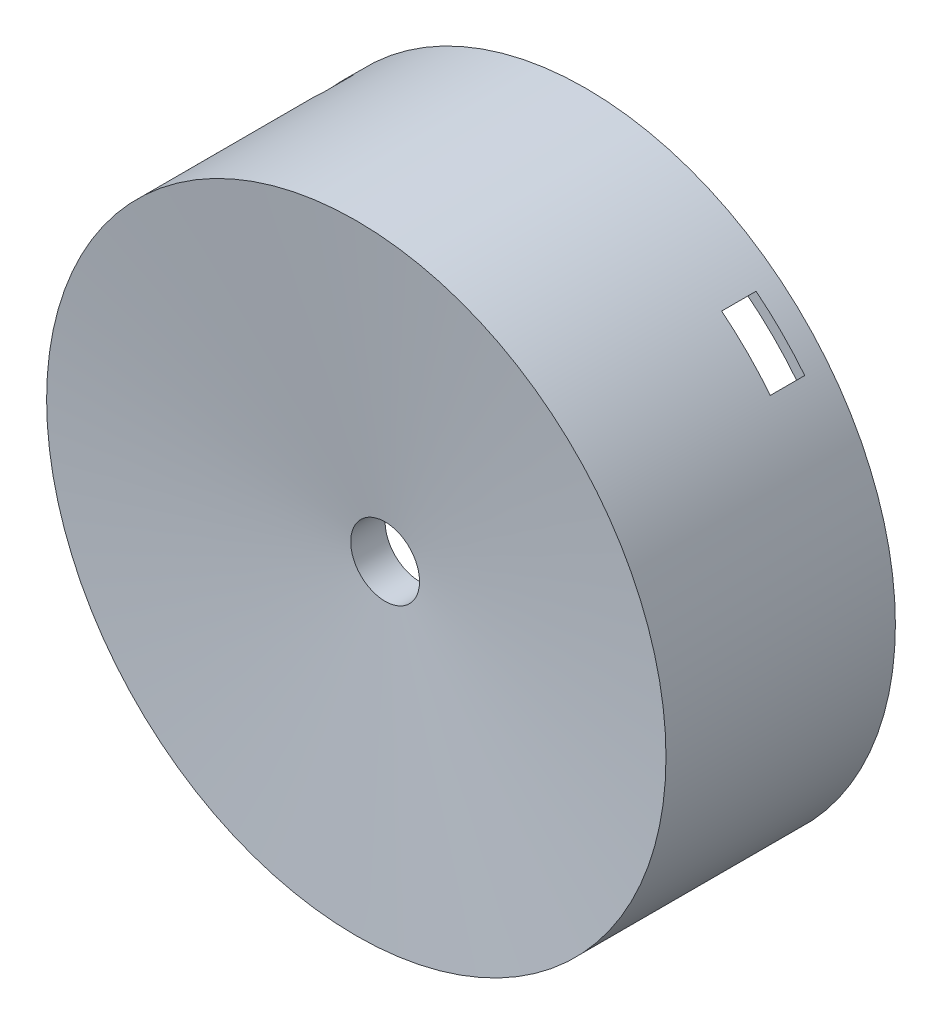
from build123d import *

# Parameters (mm, degrees)
BOSS_EXTRU_4_START      = -13.837467
BOSS_EXTRU_4_DEPTH      = 13.837467
ENL_V_MAT_EXTRU_2_DEPTH = 3
ENL_V_MAT_EXTRU_3_DEPTH = 3


with BuildPart() as part:
    # Esquisse3 → Révolution1 (revolve)
    with BuildSketch(Plane(origin=(0, 0, 0), x_dir=(1, 0, 0), z_dir=(0, 1, 0))):
        Polygon((-27, 18.413817), (-27, 38.413817), (-26, 38.413817), (-26, 33.413817), (-25.5, 33.413817), (-25.5, 19.57635), (-3.5, 21.879977), (-3.5, 23.926865), (-3, 23.926865), (-3, 20.926865), align=None)
    revolve(axis=Axis((0, 0, 0), (0, 0, -1)))

    # Esquisse7 → Boss.-Extru.4 (add)
    with BuildSketch(Plane(origin=(0, 0, -33.413817), x_dir=(-1, 0, 0), z_dir=(0, 0, -1)).offset(BOSS_EXTRU_4_START)):
        Polygon((22.922963, -1), (25.922963, -2), (25.922963, 2), (22.922963, 1), align=None)
        Polygon((-21.922971, 0.990749), (-24.919872, 2), (-24.932213, -1.999981), (-21.929142, -1.009241), align=None)
        Polygon((19.48304, 10.094527), (22.581242, 10.727885), (20.581931, 14.192384), (18.483384, 11.826776), align=None)
        Polygon((-18.489986, 11.81993), (-20.581242, 14.191987), (-22.591207, 10.733658), (-19.494969, 10.090766), align=None)
        Polygon((18.497253, -11.813544), (20.581242, -14.191987), (22.363748, -11.146506), (22.601778, -10.739823), (19.507521, -10.087462), align=None)
        Polygon((-19.481096, -10.10411), (-22.581242, -10.727885), (-20.592654, -14.19855), (-18.486802, -11.839443), align=None)
    extrude(amount=BOSS_EXTRU_4_DEPTH)

    # Esquisse8 → Enlèv. mat.-Extru.2 (cut)
    with BuildSketch(Plane(origin=(0, 0, -33.413817), x_dir=(-1, 0, 0), z_dir=(0, 0, -1))):
        Polygon((10.264649, 12.385969), (23.674383, 25.795703), (25.795703, 23.674383), (12.385969, 10.264649), align=None)
    extrude(amount=ENL_V_MAT_EXTRU_2_DEPTH, mode=Mode.SUBTRACT)

    # Esquisse9 → Enlèv. mat.-Extru.3 (cut)
    with BuildSketch(Plane(origin=(0, 0, -33.413817), x_dir=(-1, 0, 0), z_dir=(0, 0, -1))):
        Polygon((-12.020815, 16.263456), (-19.091883, 23.334524), (-23.334524, 19.091883), (-16.263456, 12.020815), align=None)
    extrude(amount=ENL_V_MAT_EXTRU_3_DEPTH, mode=Mode.SUBTRACT)


solid = part.part
